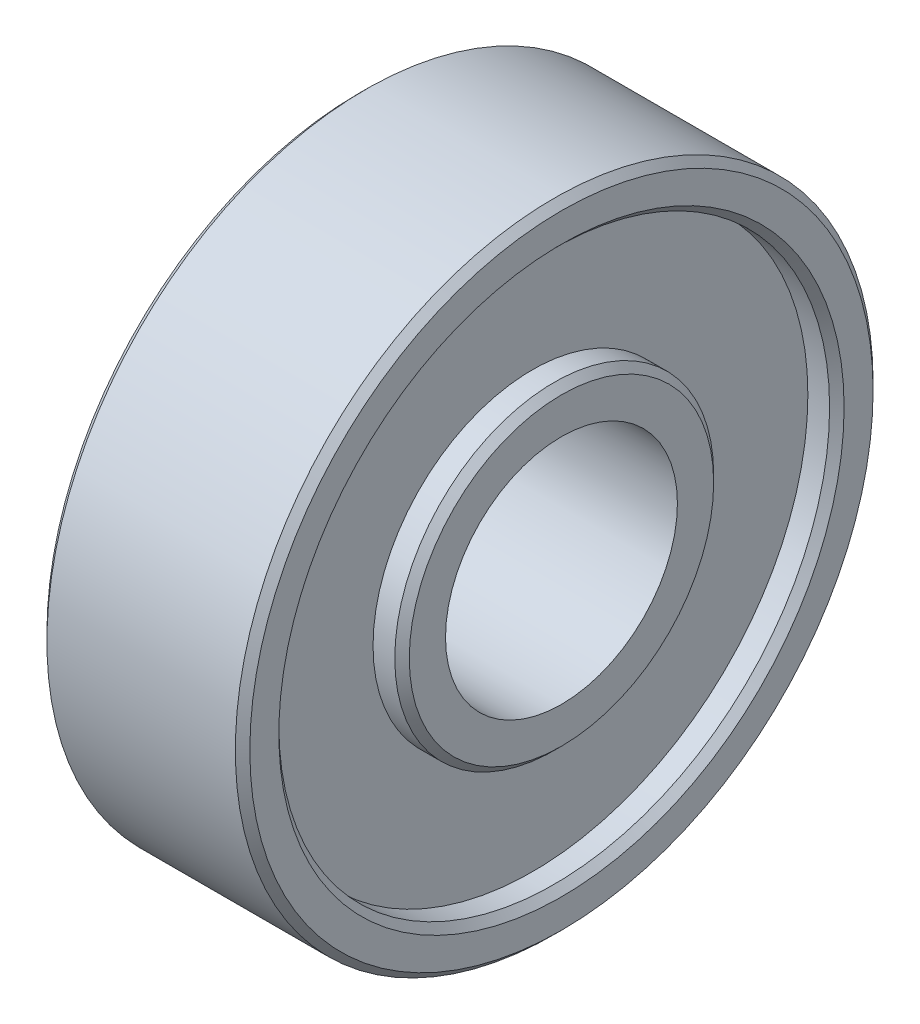
from build123d import *

# Parameters (mm, degrees)
SKETCH1_R          = 11
SKETCH1_R_2        = 4
EXTRUDE1_DEPTH     = 7
CHAMFER1_SIZE      = 0.25
SKETCH2_R          = 9.5
SKETCH2_R_2        = 5.5
CUT_EXTRUDE1_DEPTH = 1
SKETCH3_R          = 9.5
SKETCH3_R_2        = 5.5
CUT_EXTRUDE2_DEPTH = 1
CHAMFER2_SIZE      = 0.25


with BuildPart() as part:
    # Sketch1 → Extrude1 (new body)
    with BuildSketch(Plane(origin=(0, 0, 0), x_dir=(0, 0, -1), z_dir=(1, 0, 0))):
        Circle(SKETCH1_R)
        Circle(SKETCH1_R_2, mode=Mode.SUBTRACT)
    extrude(amount=EXTRUDE1_DEPTH)

    # Chamfer1
    chamfer1_edges = [part.edges().sort_by_distance(p)[0] for p in [
        (0, 0, 11),
        (7, 0, 11),
        (0, 0, 4),
    ]]
    chamfer(chamfer1_edges, length=CHAMFER1_SIZE)

    # Sketch2 → Cut-Extrude1 (cut)
    with BuildSketch(Plane.ZY):
        Circle(SKETCH2_R)
        Circle(SKETCH2_R_2, mode=Mode.SUBTRACT)
    extrude(amount=-CUT_EXTRUDE1_DEPTH, mode=Mode.SUBTRACT)

    # Sketch3 → Cut-Extrude2 (cut)
    with BuildSketch(Plane(origin=(7, 0, 0), x_dir=(0, 0, -1), z_dir=(1, 0, 0))):
        with Locations(Location((0, 0, 0), (0, 0, 180))):  # turned: the seam where the file's is
            Circle(SKETCH3_R)
        with Locations(Location((0, 0, 0), (0, 0, 180))):  # turned: the seam where the file's is
            Circle(SKETCH3_R_2, mode=Mode.SUBTRACT)
    extrude(amount=-CUT_EXTRUDE2_DEPTH, mode=Mode.SUBTRACT)

    # Chamfer2
    chamfer2_edges = [part.edges().sort_by_distance(p)[0] for p in [
        (0, 0, -9.5),
        (0, 0, -5.5),
        (7, 0, -9.5),
        (7, 0, -5.5),
    ]]
    chamfer(chamfer2_edges, length=CHAMFER2_SIZE)


solid = part.part
